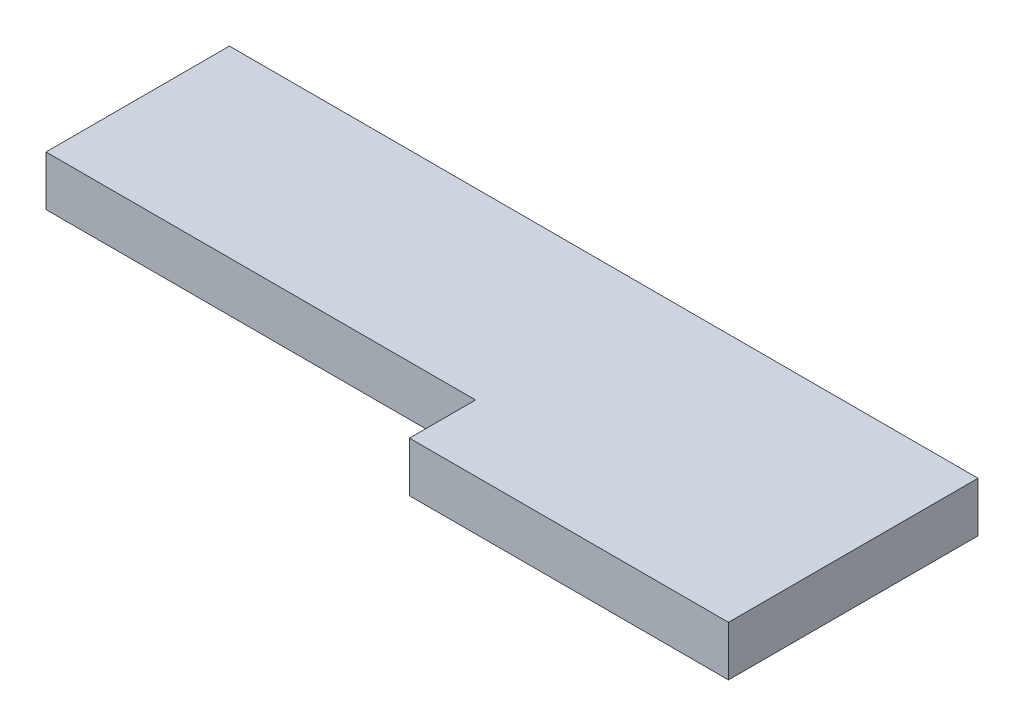
from build123d import *

# Parameters (mm, degrees)
BOSS_EXTRUDE1_DEPTH = 10


with BuildPart() as part:
    # Sketch1 → Boss-Extrude1 (new body)
    with BuildSketch(Plane(origin=(0, 0, 0), x_dir=(1, 0, 0), z_dir=(0, 1, 0))):
        Polygon((-123.913043478, -0.951086957), (-123.913043478, -37.707292157), (-37.83687048, -37.707292157), (-37.83687048, -50.951086957), (26.086956522, -50.951086957), (26.086956522, -0.951086957), align=None)
    extrude(amount=BOSS_EXTRUDE1_DEPTH)


solid = part.part
